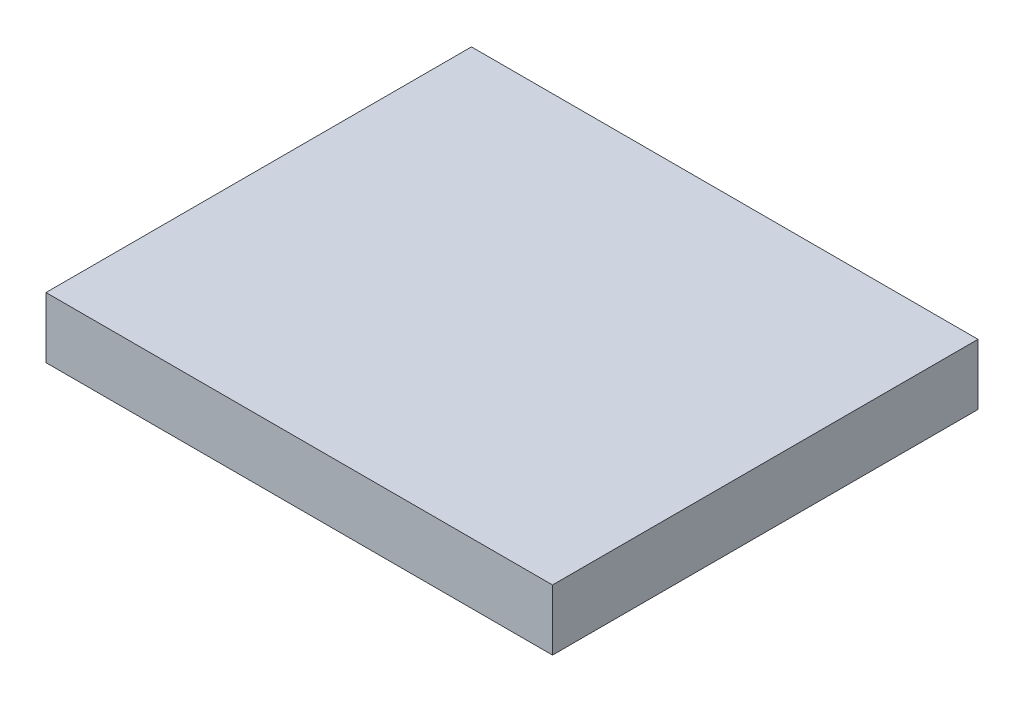
from build123d import *

# Parameters (mm, degrees)
SKETCH1_W           = 39.6875
SKETCH1_H           = 33.3375
BOSS_EXTRUDE1_DEPTH = 4.7625


with BuildPart() as part:
    # Sketch1 → Boss-Extrude1 (new body)
    with BuildSketch(Plane(origin=(0, 0, 0), x_dir=(1, 0, 0), z_dir=(0, 1, 0))):
        Rectangle(SKETCH1_W, SKETCH1_H)
    extrude(amount=BOSS_EXTRUDE1_DEPTH)


solid = part.part
